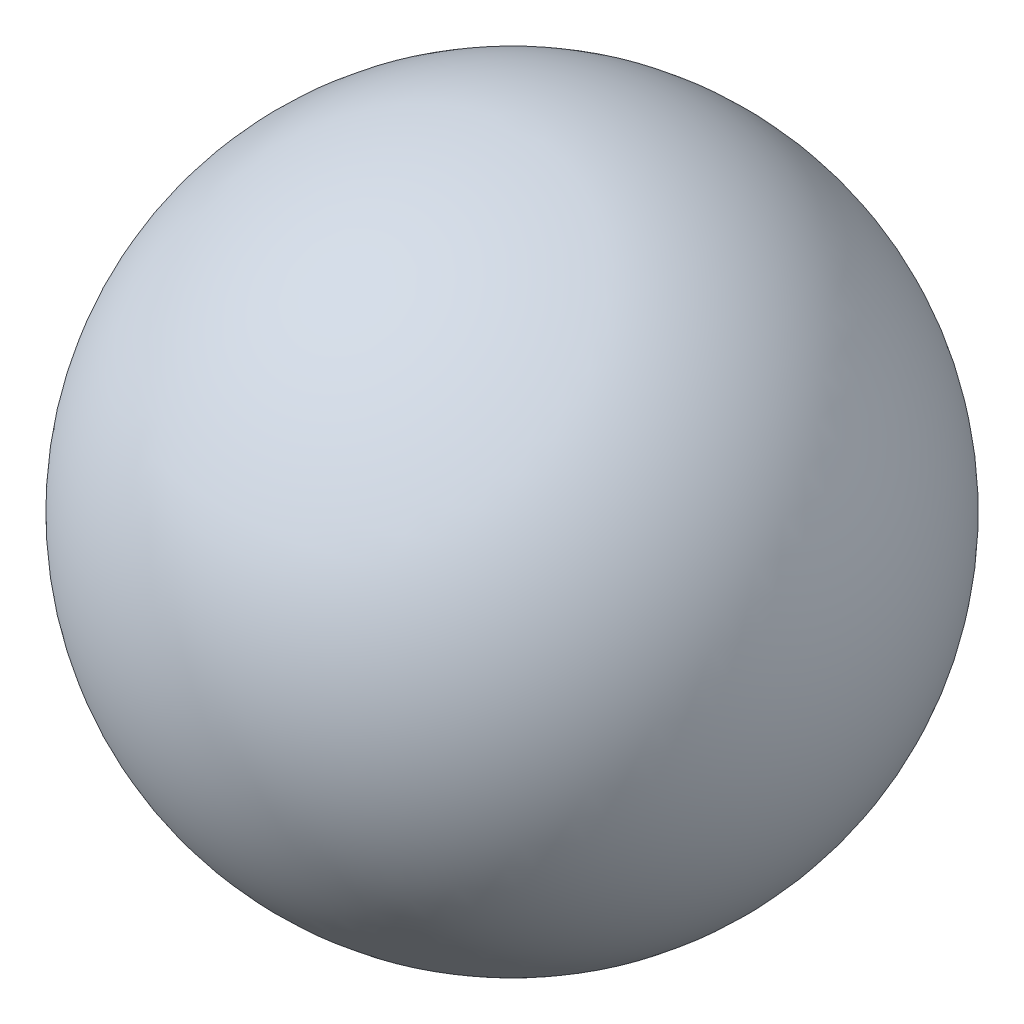
from build123d import *


with BuildPart() as part:
    # Sketch2 → Revolve1 (revolve)
    with BuildSketch(Plane.XY):
        with BuildLine():
            Line((0, 88.9), (0, -88.9))
            ThreePointArc((0, -88.9), (-88.9, 0), (0, 88.9))
        make_face()
    revolve(axis=Axis((0, 88.9, 0), (0, -1, 0)))


solid = part.part
